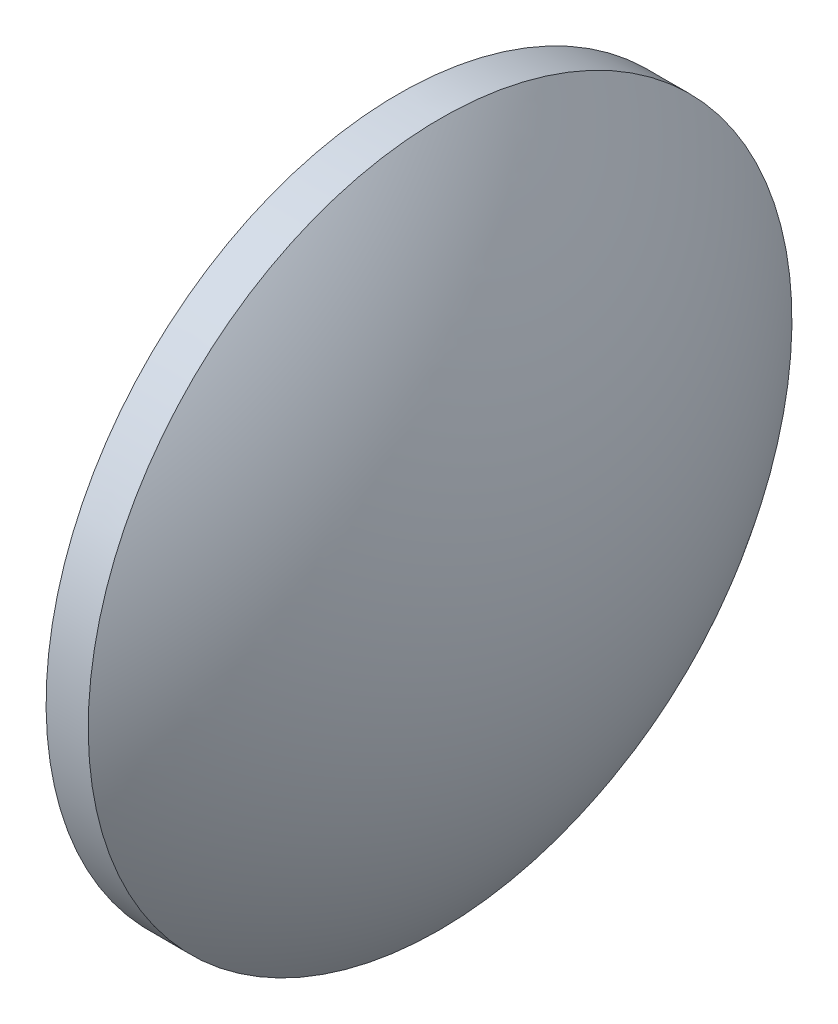
from build123d import *


with BuildPart() as part:
    # 草图1 → 旋转1 (revolve)
    with BuildSketch(Plane.XY, mode=Mode.PRIVATE) as revolve_1_sk:
        with BuildLine():
            Line((469.33354572, 46.940361342), (469.33354572, 71.940361342))
            Line((469.33354572, 71.940361342), (472.33354572, 71.940361342))
            ThreePointArc((472.33354572, 71.940361342), (478.602865239, 60.121362666), (480.76353975, 46.918159169))
            Line((480.76353975, 46.918159169), (469.33354572, 46.940361342))
        make_face()
    revolve(revolve_1_sk.sketch.rotate(Axis((464.685698668, 46.949389544, 0), (0.999998113, -0.001942445, 0)), 180), axis=Axis((464.685698668, 46.949389544, 0), (0.999998113, -0.001942445, 0)))  # turned: the seam where the file's is


solid = part.part
